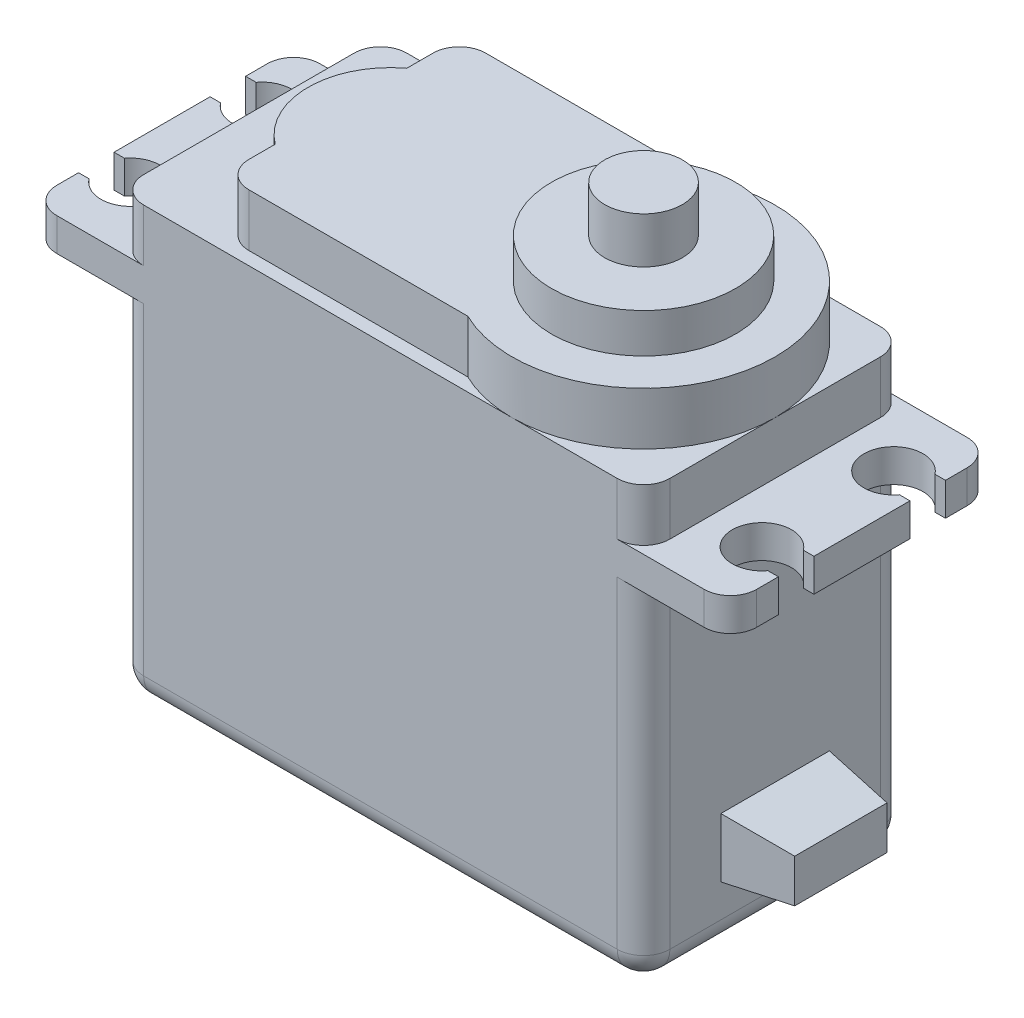
from build123d import *

# Parameters (mm, degrees)
BOSS_EXTRUDE1_DEPTH = 2.5
SKETCH2_W           = 40
SKETCH2_H           = 20
BOSS_EXTRUDE2_DEPTH = 4
SKETCH3_W           = 40
SKETCH3_H           = 20
BOSS_EXTRUDE3_DEPTH = 26.5
BOSS_EXTRUDE4_DEPTH = 4
SKETCH5_R           = 7
BOSS_EXTRUDE5_DEPTH = 3
SKETCH6_R           = 2.95
BOSS_EXTRUDE6_DEPTH = 3.5
FILLET1_R           = 2
SKETCH7_W           = 8.25
SKETCH7_H           = 4.5
BOSS_EXTRUDE7_DEPTH = 5
DRAFT3_ANGLE        = 7


with BuildPart() as part:
    # Sketch1 → Boss-Extrude1 (new body)
    with BuildSketch(Plane(origin=(0, 0, 0), x_dir=(1, 0, 0), z_dir=(0, 1, 0))):
        with BuildLine():
            ThreePointArc((25.8, 3.65), (21.75, 5), (25.8, 6.35))
            Line((25.8, 6.35), (26.6, 6.35))
            Line((26.6, 6.35), (26.6, 10))
            Line((26.6, 10), (-26.6, 10))
            Line((-26.6, 10), (-26.6, 6.35))
            Line((-26.6, 6.35), (-25.8, 6.35))
            ThreePointArc((-25.8, 6.35), (-23.288487526, 7.134537421), (-21.75, 5))
            ThreePointArc((-21.75, 5), (-23.288487526, 2.865462579), (-25.8, 3.65))
            Line((-25.8, 3.65), (-26.6, 3.65))
            Line((-26.6, 3.65), (-26.6, -3.65))
            Line((-26.6, -3.65), (-25.8, -3.65))
            ThreePointArc((-25.8, -3.65), (-23.288487526, -2.865462579), (-21.75, -5))
            ThreePointArc((-21.75, -5), (-23.288487526, -7.134537421), (-25.8, -6.35))
            Line((-25.8, -6.35), (-26.6, -6.35))
            Line((-26.6, -6.35), (-26.6, -10))
            Line((-26.6, -10), (26.6, -10))
            Line((26.6, -10), (26.6, -6.35))
            Line((26.6, -6.35), (25.8, -6.35))
            ThreePointArc((25.8, -6.35), (21.75, -5), (25.8, -3.65))
            Line((25.8, -3.65), (26.6, -3.65))
            Line((26.6, -3.65), (26.6, 3.65))
            Line((26.6, 3.65), (25.8, 3.65))
        make_face()
    extrude(amount=BOSS_EXTRUDE1_DEPTH)

    # Sketch2 → Boss-Extrude2 (add)
    with BuildSketch(Plane(origin=(0, 2.5, 0), x_dir=(1, 0, 0), z_dir=(0, 1, 0))):
        Rectangle(SKETCH2_W, SKETCH2_H)
    extrude(amount=BOSS_EXTRUDE2_DEPTH)

    # Sketch3 → Boss-Extrude3 (add)
    with BuildSketch(Plane.XZ):
        Rectangle(SKETCH3_W, SKETCH3_H)
    extrude(amount=BOSS_EXTRUDE3_DEPTH)

    # Sketch4 → Boss-Extrude4 (add)
    with BuildSketch(Plane(origin=(0, 6.5, 0), x_dir=(1, 0, 0), z_dir=(0, 1, 0))):
        with BuildLine():
            ThreePointArc((5.641101056, -9), (0, 0), (5.641101056, 9))
            Line((5.641101056, 9), (-13, 9))
            Line((-13, 9), (-13, 5))
            Line((-13, 5), (-13, -5))
            Line((-13, -5), (-13, -9))
            Line((-13, -9), (5.641101056, -9))
        make_face()
        with BuildLine():
            ThreePointArc((20, 0), (15.310885546, 8.473163206), (5.641101056, 9))
            Line((5.641101056, 9), (5.641101056, -9))
            ThreePointArc((5.641101056, -9), (15.310885546, -8.473163206), (20, 0))
        make_face()
        with BuildLine():
            Line((5.641101056, -9), (5.641101056, 9))
            ThreePointArc((5.641101056, 9), (0, 0), (5.641101056, -9))
        make_face()
        with BuildLine():
            Line((-13, -5), (-13, 5))
            ThreePointArc((-13, 5), (-15.5, 0), (-13, -5))
        make_face()
    extrude(amount=BOSS_EXTRUDE4_DEPTH)

    # Sketch5 → Boss-Extrude5 (add)
    with BuildSketch(Plane(origin=(0, 10.5, 0), x_dir=(1, 0, 0), z_dir=(0, 1, 0))):
        with Locations((10, 0)):
            Circle(SKETCH5_R)
    extrude(amount=BOSS_EXTRUDE5_DEPTH)

    # Sketch6 → Boss-Extrude6 (add)
    with BuildSketch(Plane(origin=(0, 13.5, 0), x_dir=(1, 0, 0), z_dir=(0, 1, 0))):
        with Locations((10, 0)):
            Circle(SKETCH6_R)
    extrude(amount=BOSS_EXTRUDE6_DEPTH)

    # Fillet1
    fillet1_edges = [part.edges().sort_by_distance(p)[0] for p in [
        (-26.6, 1.25, -10),
        (26.6, 1.25, -10),
        (26.6, 1.25, 10),
        (-26.6, 1.25, 10),
        (-20, 4.5, -10),
        (-20, 4.5, 10),
        (20, 4.5, 10),
        (20, 4.5, -10),
        (20, -13.25, 10),
        (-20, -26.5, 0),
        (-20, -13.25, 10),
        (0, -26.5, -10),
        (-20, -13.25, -10),
        (20, -13.25, -10),
        (0, -26.5, 10),
        (20, -26.5, 0),
        (-13, 8.5, 9),
        (-13, 8.5, -9),
    ]]
    fillet(fillet1_edges, radius=FILLET1_R)

    # Sketch7 → Boss-Extrude7 (add)
    with BuildSketch(Plane(origin=(20, 0, 0), x_dir=(0, 0, -1), z_dir=(1, 0, 0))):
        with Locations((0, -19.75000011)):
            Rectangle(SKETCH7_W, SKETCH7_H)
    extrude(amount=BOSS_EXTRUDE7_DEPTH)

    # Draft3
    draft3_faces = [part.faces().sort_by_distance(p)[0] for p in [
        (22.5, -22.00000011, 0),
        (22.5, -19.75000011, 4.125),
        (22.5, -19.75000011, -4.125),
        (22.5, -17.50000011, 0),
    ]]
    draft(draft3_faces, Plane(origin=(20, -26.5, -10), x_dir=(0, 0, 1), z_dir=(1, 0, 0)), DRAFT3_ANGLE)


solid = part.part
